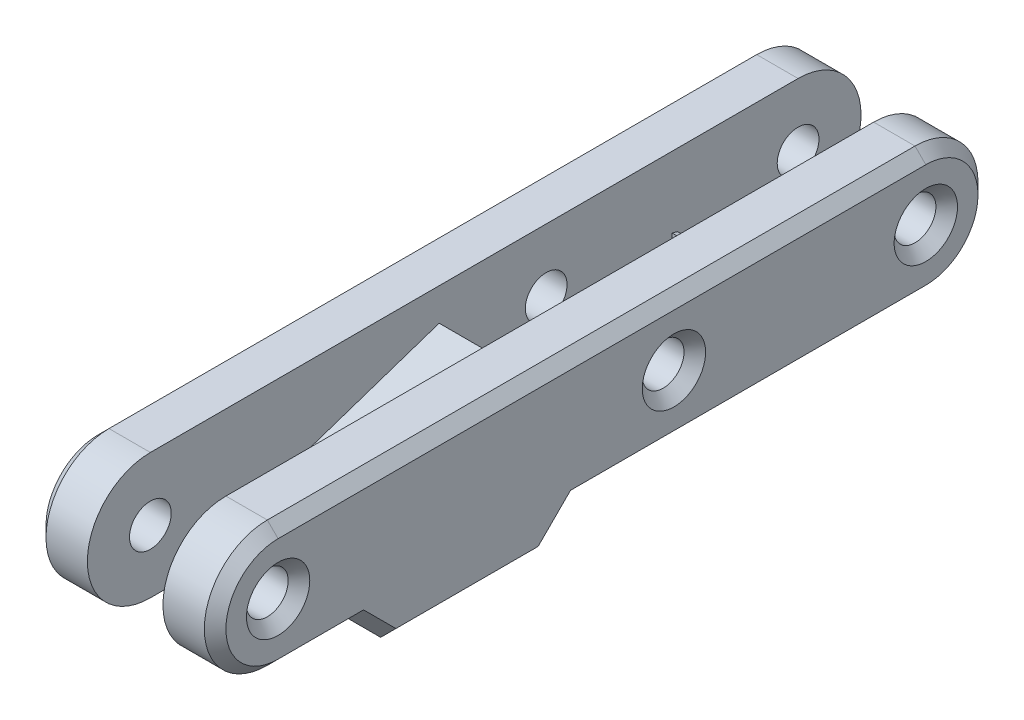
from build123d import *
from OCP.BRepFilletAPI import BRepFilletAPI_MakeChamfer

# Parameters (mm, degrees)
SKETCH_1_R          = 1.16
EXTRUDE_1_DEPTH     = 5
CUT_EXTRUDE_1_DEPTH = 2.1
EXTRUDE_2_DEPTH     = 2.5
EXTRUDE_3_DEPTH     = 5
CHAMFER_2_SIZE      = 0.6
CHAMFER_2_SIZE2     = 0.4738544759401763
CHAMFER_2_SIZE2_2   = 0.4738544759401755
CHAMFER_2_SIZE2_3   = 0.4397595135435583
CHAMFER_2_SIZE2_4   = 0.43975951354355786


with BuildPart() as part:
    # 草图1 → 凸台-拉伸1 (new, symmetric)
    with BuildSketch(Plane(origin=(0, 0, 0), x_dir=(0, 0, -1), z_dir=(1, 0, 0))):
        with BuildLine():
            Line((-18.000000000000004, 3.500000000000003), (18.000000000000004, 3.500000000000003))
            ThreePointArc((18.000000000000004, 3.500000000000003), (21.50000000000001, 3.31e-15), (18.000000000000004, -3.500000000000003))
            Line((18.000000000000004, -3.500000000000003), (-18.000000000000004, -3.500000000000003))
            ThreePointArc((-18.000000000000004, -3.500000000000003), (-21.500000000000004, 3.74e-15), (-18.000000000000004, 3.500000000000003))
        make_face()
        with Locations((18.000000000000004, 3.31e-15)):
            Circle(SKETCH_1_R, mode=Mode.SUBTRACT)
        with Locations((4, -2.2e-15)):
            Circle(SKETCH_1_R, mode=Mode.SUBTRACT)
        with Locations((-18.000000000000004, 3.31e-15)):
            Circle(SKETCH_1_R, mode=Mode.SUBTRACT)
    extrude(amount=EXTRUDE_1_DEPTH, both=True)

    # 草图2 → 切除-拉伸1 (cut, symmetric)
    with BuildSketch(Plane(origin=(0, 0, 0), x_dir=(0, 0, -1), z_dir=(1, 0, 0))):
        with BuildLine():
            Line((-18.000000000000004, -3.4999999999999996), (18.000000000000004, -3.4999999999999996))
            ThreePointArc((18.000000000000004, -3.4999999999999996), (21.500000000000007, 3.31e-15), (18.000000000000004, 3.500000000000005))
            Line((18.000000000000004, 3.500000000000005), (-18.000000000000004, 3.5000000000000067))
            ThreePointArc((-18.000000000000004, 3.5000000000000067), (-21.500000000000007, 3.74e-15), (-18.000000000000004, -3.4999999999999996))
        make_face()
    extrude(amount=CUT_EXTRUDE_1_DEPTH, both=True, mode=Mode.SUBTRACT)


with BuildPart() as cut_extrude_1_piece_1:
    # of the separate pieces the step leaves, piece 1, a body of its own (cut_extrude_1_pieces)
    add(part.part.solids().sort_by_distance((-5, 3.5, 18))[0])



with BuildPart() as cut_extrude_1_piece_2:
    # of the separate pieces the step leaves, piece 2, a body of its own (cut_extrude_1_pieces)
    add(part.part.solids().sort_by_distance((2.1, 3.5, 18))[0])


with BuildPart() as cut_extrude_1_piece_1_1:
    add(cut_extrude_1_piece_1.part)

    add(cut_extrude_1_piece_2.part)  # 凸台-拉伸2 merges 切除-拉伸1 piece 2
    # 草图2<4> → 凸台-拉伸2 (add, symmetric)
    with BuildSketch(Plane(origin=(0, 0, 0), x_dir=(0, 0, -1), z_dir=(1, 0, 0))):
        Polygon((-16.886363638073764, -3.3181039847171285), (-17.42832680730712, -3.500000000000003), (-1.5000000000000036, -3.4999999999999996), (-1.5000000000000053, 1.8459337107187295), align=None)
        Polygon((13.000000000000002, -3.5000000000000013), (11.000000000000002, -8.6e-16), (11.000000000000004, -3.4999999999999996), align=None)
    extrude(amount=EXTRUDE_2_DEPTH, both=True)

    # 草图3 → 凸台-拉伸3 (add, symmetric)
    with BuildSketch(Plane(origin=(0, 0, 0), x_dir=(0, 0, -1), z_dir=(1, 0, 0))):
        Polygon((-1.5000000000000049, -3.4999999999999996), (-13.500000000000005, -3.5000000000000027), (-11.699999999999978, -5.3000000000000025), (-3.3000000000000287, -5.300000000000003), align=None)
    extrude(amount=EXTRUDE_3_DEPTH, both=True)

    # 倒角2: one chamfer whose edges measure the first distance from different faces: ONE call of the kernel's chamfer builder (chamfer() names one face for all edges)
    chamfer_2_edges_1 = [cut_extrude_1_piece_1_1.edges().sort_by_distance(p)[0] for p in [
        (-5, -4.4e-16, 21.500000000000004),
        (-5, -3.500000000000003, 15.750000000000004),
        (-5, -1.2e-16, -21.50000000000001),
        (-5, 3.500000000000003, 0),
        (-5, 3.45e-15, -16.840000000000003),
        (-5, -2.06e-15, -2.84),
        (-5, 3.45e-15, 19.160000000000004),
        (5, 3.45e-15, -16.840000000000003),
        (5, -2.06e-15, -2.84),
        (5, -4.4e-16, 21.500000000000004),
        (5, -3.500000000000003, 15.750000000000004),
        (5, -1.2e-16, -21.50000000000001),
        (5, 3.500000000000003, 0),
        (5, 3.45e-15, 19.160000000000004),
        (4.4e-16, -3.4999999999999996, -11.000000000000004),
        (5, -3.500000000000003, -8.25),
        (-5, -3.500000000000003, -8.25),
        (-5, -4.400000000000002, 12.59999999999999),
        (-5, -5.3000000000000025, 7.5000000000000036),
        (-5, -4.400000000000001, 2.400000000000017),
        (5, -4.400000000000002, 12.59999999999999),
        (5, -5.3000000000000025, 7.5000000000000036),
        (5, -4.400000000000001, 2.400000000000017),
    ]]
    chamfer_2_edges_2 = [cut_extrude_1_piece_1_1.edges().sort_by_distance(p)[0] for p in [
        (4.4e-16, 1.8459337107187292, 1.5000000000000053),
    ]]
    chamfer_2_side_2 = [cut_extrude_1_piece_1_1.faces().sort_by_distance(p)[0] for p in [
        (1e-17, -0.827033144640636, 1.500000000000005),
    ]]
    chamfer_2_edges_3 = [cut_extrude_1_piece_1_1.edges().sort_by_distance(p)[0] for p in [
        (4.4e-16, -3.5000000000000013, 17.42832680730712),
    ]]
    chamfer_2_side_3 = [cut_extrude_1_piece_1_1.faces().sort_by_distance(p)[0] for p in [
        (-2e-17, -0.8270331446406359, 9.464163403653561),
    ]]
    chamfer_2_edges_4 = [cut_extrude_1_piece_1_1.edges().sort_by_distance(p)[0] for p in [
        (4.4e-16, -3.5000000000000013, -13.000000000000002),
    ]]
    chamfer_2_side_4 = [cut_extrude_1_piece_1_1.faces().sort_by_distance(p)[0] for p in [
        (4.780853929991888, -3.500000000000003, -8.25),
    ]]
    chamfer_2_edges_5 = [cut_extrude_1_piece_1_1.edges().sort_by_distance(p)[0] for p in [
        (-4.4e-16, -8.6e-16, -11.000000000000002),
    ]]
    chamfer_2_side_5 = [cut_extrude_1_piece_1_1.faces().sort_by_distance(p)[0] for p in [
        (-1e-17, -1.7500000000000009, -12.000000000000002),
    ]]
    chamfer_2 = BRepFilletAPI_MakeChamfer(cut_extrude_1_piece_1_1.part.solid().wrapped)
    for e in chamfer_2_edges_1:
        chamfer_2.Add(CHAMFER_2_SIZE, e.wrapped)
    for e in chamfer_2_edges_2:
        chamfer_2.Add(CHAMFER_2_SIZE, CHAMFER_2_SIZE2, e.wrapped, chamfer_2_side_2[0].wrapped)  # the first distance lies on this face
    for e in chamfer_2_edges_3:
        chamfer_2.Add(CHAMFER_2_SIZE, CHAMFER_2_SIZE2_2, e.wrapped, chamfer_2_side_3[0].wrapped)  # the first distance lies on this face
    for e in chamfer_2_edges_4:
        chamfer_2.Add(CHAMFER_2_SIZE, CHAMFER_2_SIZE2_3, e.wrapped, chamfer_2_side_4[0].wrapped)  # the first distance lies on this face
    for e in chamfer_2_edges_5:
        chamfer_2.Add(CHAMFER_2_SIZE, CHAMFER_2_SIZE2_4, e.wrapped, chamfer_2_side_5[0].wrapped)  # the first distance lies on this face
    add(Compound.cast(chamfer_2.Shape()), mode=Mode.REPLACE)


solid = cut_extrude_1_piece_1_1.part
